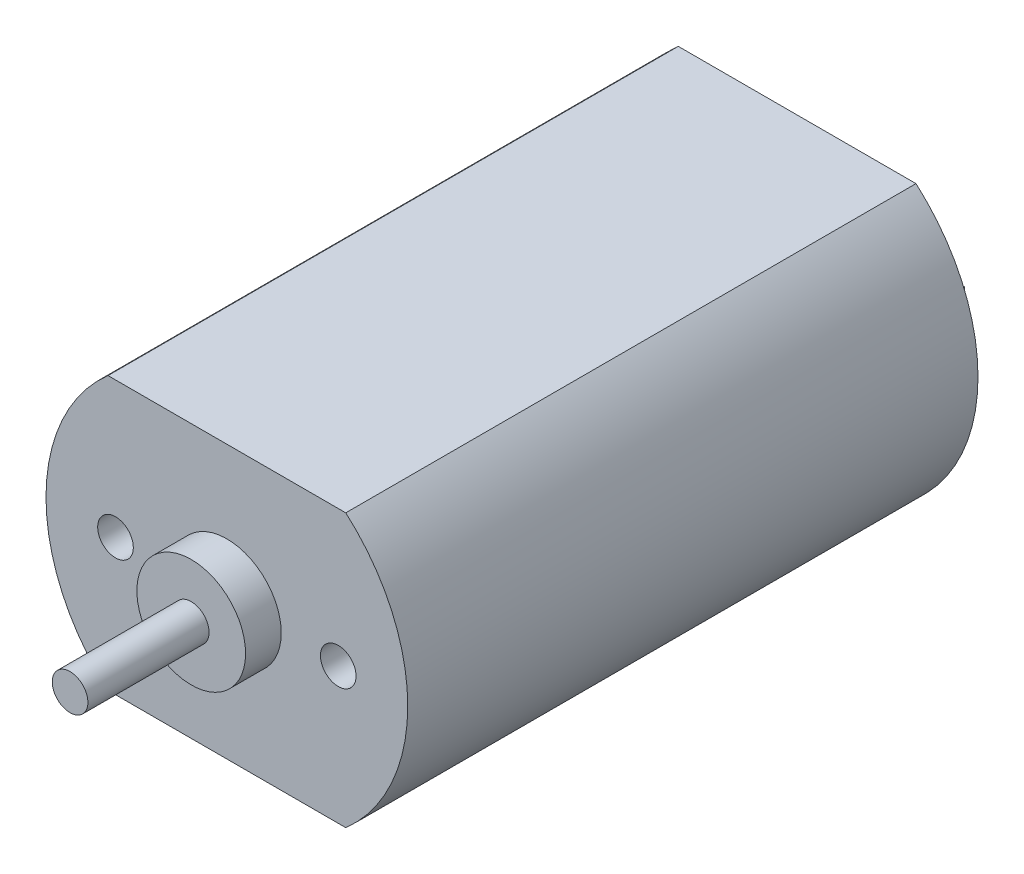
from build123d import *

# Parameters (mm, degrees)
SKETCH_1_R          = 10.15
EXTRUDE_1_DEPTH     = 32
CUT_EXTRUDE_1_DEPTH = 36.071997377
SKETCH_4_W          = 0.4
SKETCH_4_H          = 2
EXTRUDE_2_DEPTH     = 3
SKETCH_6_R          = 1
CUT_EXTRUDE_2_DEPTH = 4
SKETCH_6_4_R        = 3.05
EXTRUDE_3_DEPTH     = 2
SKETCH_7_R          = 1
EXTRUDE_4_DEPTH     = 6.8


with BuildPart() as part:
    # 草图1 → 凸台-拉伸1 (new body)
    with BuildSketch(Plane.XY):
        Circle(SKETCH_1_R)
    extrude(amount=EXTRUDE_1_DEPTH)

    # 草图3 → 切除-拉伸1 (cut, through all)
    with BuildSketch(Plane.XY.offset(32)):
        with BuildLine():
            Line((6.670832032, -7.65), (-6.670832032, -7.65))
            ThreePointArc((-6.670832032, -7.65), (0, -10.15), (6.670832032, -7.65))
        make_face()
        with BuildLine():
            ThreePointArc((6.670832032, 7.65), (0, 10.15), (-6.670832032, 7.65))
            Line((-6.670832032, 7.65), (6.670832032, 7.65))
        make_face()
    extrude(amount=-CUT_EXTRUDE_1_DEPTH, mode=Mode.SUBTRACT)

    # 草图4 → 凸台-拉伸2 (add)
    with BuildSketch(Plane(origin=(0, 0, 0), x_dir=(-1, 0, 0), z_dir=(0, 0, -1))):
        with Locations((6.2, 0)):
            Rectangle(SKETCH_4_W, SKETCH_4_H)
        with Locations((-6.2, 0)):
            Rectangle(SKETCH_4_W, SKETCH_4_H)
    extrude(amount=EXTRUDE_2_DEPTH)

    # 草图6 → 切除-拉伸2 (cut)
    with BuildSketch(Plane.XY.offset(32)):
        with Locations((-6.25, 0)):
            Circle(SKETCH_6_R)
        with Locations((6.25, 0)):
            Circle(SKETCH_6_R)
    extrude(amount=-CUT_EXTRUDE_2_DEPTH, mode=Mode.SUBTRACT)

    # 草图6<4> → 凸台-拉伸3 (add)
    with BuildSketch(Plane.XY.offset(32)):
        Circle(SKETCH_6_4_R)
    extrude(amount=EXTRUDE_3_DEPTH)

    # 草图7 → 凸台-拉伸4 (add)
    with BuildSketch(Plane.XY.offset(34)):
        Circle(SKETCH_7_R)
    extrude(amount=EXTRUDE_4_DEPTH)


solid = part.part
